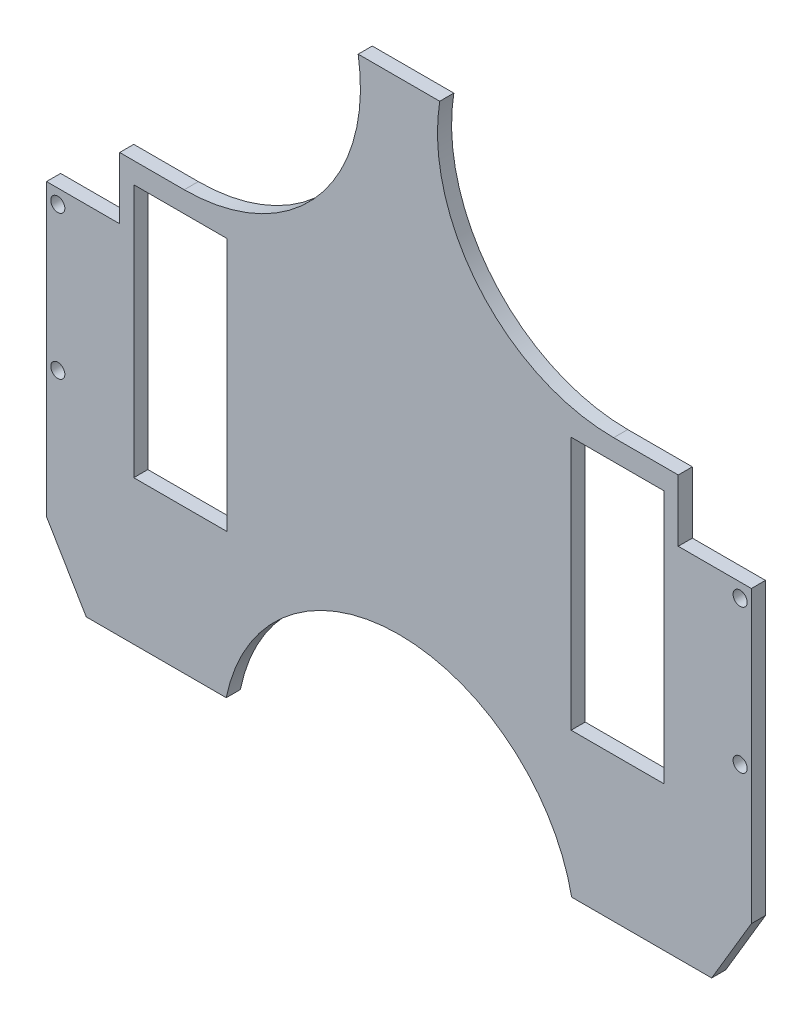
from build123d import *

# Parameters (mm, degrees)
SKETCH1_W           = 250
SKETCH1_H           = 221.085663757
SKETCH1_R           = 2.5
SKETCH1_W_2         = 33
SKETCH1_H_2         = 90
BOSS_EXTRUDE1_DEPTH = 5
SKETCH6_R           = 62.5
CUT_EXTRUDE4_DEPTH  = 6


with BuildPart() as part:
    # Sketch1 → Boss-Extrude1 (new body)
    with BuildSketch(Plane.XY):
        with Locations((-3368.041949546, -177.462013972)):
            Rectangle(SKETCH1_W, SKETCH1_H)
        with Locations((-3489.041949546, -217.319182093)):
            Circle(SKETCH1_R, mode=Mode.SUBTRACT)
        with Locations((-3489.041949546, -166.319182093)):
            Circle(SKETCH1_R, mode=Mode.SUBTRACT)
        with Locations((-3247.041949546, -166.319182093)):
            Circle(SKETCH1_R, mode=Mode.SUBTRACT)
        with Locations((-3247.041949546, -217.319182093)):
            Circle(SKETCH1_R, mode=Mode.SUBTRACT)
        with Locations((-3445.601949546, -191.819182093)):
            Rectangle(SKETCH1_W_2, SKETCH1_H_2, mode=Mode.SUBTRACT)
        with Locations((-3290.481949546, -191.819182093)):
            Rectangle(SKETCH1_W_2, SKETCH1_H_2, mode=Mode.SUBTRACT)
    extrude(amount=BOSS_EXTRUDE1_DEPTH)

    # Sketch6 → Cut-Extrude4 (cut, through all)
    with BuildSketch(Plane.XY):
        with Locations((-3368.041949546, -300.417289182)):
            Circle(SKETCH6_R)
        Polygon((-3503.457885375, -270.451546314), (-3493.041949546, -264.270843991), (-3478.958452604, -288.00484585), (-3489.374388434, -294.185548172), align=None)
        with BuildLine():
            Line((-3493.041949546, -161.319182093), (-3493.041949546, -66.919182093))
            Line((-3493.041949546, -66.919182093), (-3382.503777097, -66.919182093))
            ThreePointArc((-3382.503777097, -66.919182093), (-3396.600008581, -117.423811459), (-3444.198590493, -139.419182093))
            Line((-3444.198590493, -139.419182093), (-3467.101949546, -139.419182093))
            Line((-3467.101949546, -139.419182093), (-3467.101949546, -161.319182093))
            Line((-3467.101949546, -161.319182093), (-3493.041949546, -161.319182093))
        make_face()
        Polygon((-3246.709510658, -294.185548172), (-3257.125446487, -288.00484585), (-3243.041949546, -264.270843991), (-3232.626013716, -270.451546314), align=None)
        with BuildLine():
            Line((-3268.981949546, -139.419182093), (-3291.885308598, -139.419182093))
            ThreePointArc((-3291.885308598, -139.419182093), (-3339.48389051, -117.423811459), (-3353.580121995, -66.919182093))
            Line((-3353.580121995, -66.919182093), (-3243.041949546, -66.919182093))
            Line((-3243.041949546, -66.919182093), (-3243.041949546, -161.319182093))
            Line((-3243.041949546, -161.319182093), (-3268.981949546, -161.319182093))
            Line((-3268.981949546, -161.319182093), (-3268.981949546, -139.419182093))
        make_face()
    extrude(amount=CUT_EXTRUDE4_DEPTH, mode=Mode.SUBTRACT)


solid = part.part
